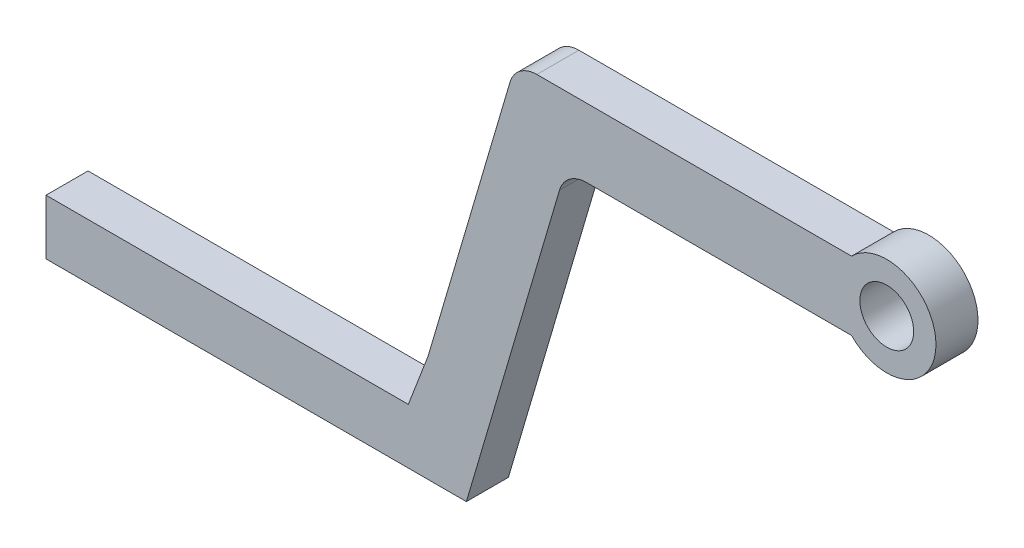
from build123d import *

# Parameters (mm, degrees)
BOSS_EXTRUDE1_DEPTH = 3.81
SKETCH2_R           = 4.458973568
BOSS_EXTRUDE2_DEPTH = 3.81
SKETCH3_R           = 2.437666758
CUT_EXTRUDE1_DEPTH  = 5.08
FILLET1_R           = 2.54
FILLET2_R           = 2.54


with BuildPart() as part:
    # Sketch1 → Boss-Extrude1 (new body)
    with BuildSketch(Plane.XY):
        Polygon((0, 30.495285818), (0, 36.722551391), (-33.610812147, 36.722551391), (-41.575749468, 9.669435316), (-43.362004736, 5.002722218), (-76.2, 5.002722218), (-76.2, 0), (-38.1, 0), (-29.121624295, 30.495285818), align=None)
    extrude(amount=BOSS_EXTRUDE1_DEPTH)

    # Sketch2 → Boss-Extrude2 (add)
    with BuildSketch(Plane.XY.offset(3.81)):
        with Locations((0, 33.608918604)):
            Circle(SKETCH2_R)
    extrude(amount=-BOSS_EXTRUDE2_DEPTH)

    # Sketch3 → Cut-Extrude1 (cut)
    with BuildSketch(Plane.XY.offset(3.81)):
        with Locations((0, 33.608918604)):
            Circle(SKETCH3_R)
    extrude(amount=-CUT_EXTRUDE1_DEPTH, mode=Mode.SUBTRACT)

    # Fillet1
    fillet1_edges = [part.edges().sort_by_distance(p)[0] for p in [
        (-33.610812147, 36.722551391, 1.905),
    ]]
    fillet(fillet1_edges, radius=FILLET1_R)

    # Fillet2
    fillet2_edges = [part.edges().sort_by_distance(p)[0] for p in [
        (-29.121624295, 30.495285818, 1.905),
    ]]
    fillet(fillet2_edges, radius=FILLET2_R)


solid = part.part
